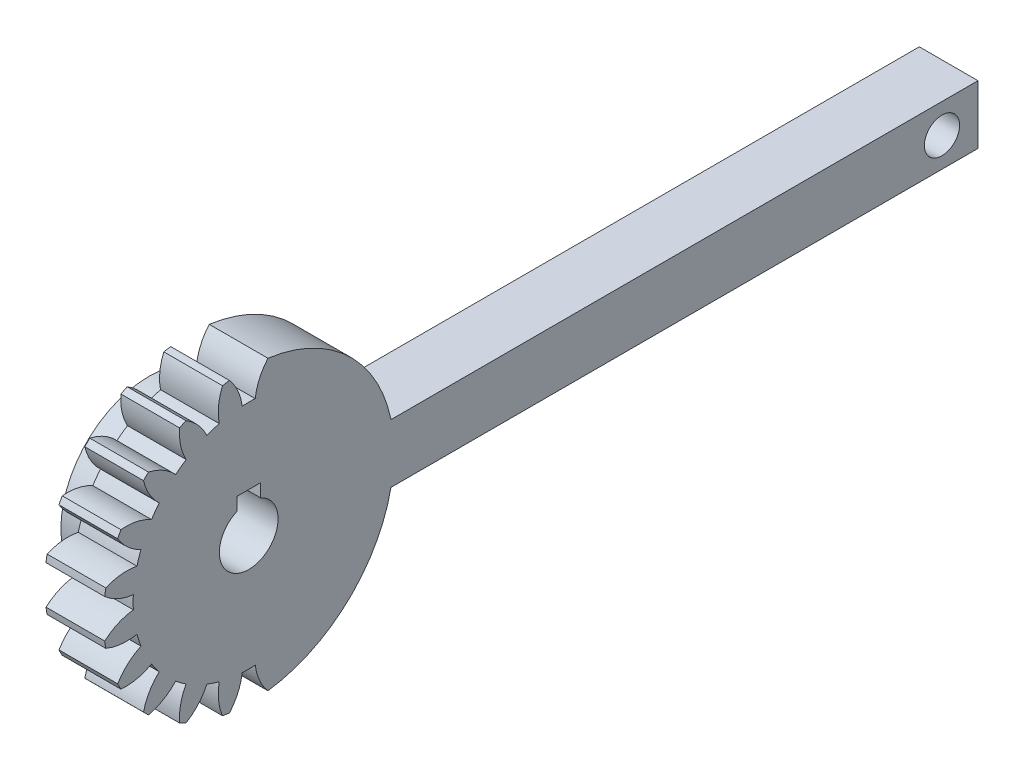
from build123d import *

# Parameters (mm, degrees)
BASPROSKE_W             = 10
BASPROSKE_H             = 24.75
TOOTHCUT_DEPTH          = 37.402266413
TEETHCUTS_COUNT         = 11
TEETHCUTS_ANGLE         = 180
HUBNEAONESKE_R          = 15
HUBNEARONE_DEPTH        = 7.0000508
BORSKE_R                = 5
BORE_DEPTH              = 10.0000508
KEYSKE_W                = 4
KEYSKE_H                = 6.8
KEYWAY_DEPTH            = 10.0000508
ESQUISSE1_W             = 100
ESQUISSE1_H             = 10
BOSS_EXTRU_1_DEPTH      = 10
ESQUISSE2_R             = 3
ENL_V_MAT_EXTRU_2_DEPTH = 10


with BuildPart() as part:
    # BasProSke → Base-Revolve (revolve)
    with BuildSketch(Plane(origin=(0, 0, 0), x_dir=(1, 0, 0), z_dir=(0, 1, 0)), mode=Mode.PRIVATE) as base_revolve_sk:
        with Locations((5, 12.375)):
            Rectangle(BASPROSKE_W, BASPROSKE_H)
    revolve(base_revolve_sk.sketch.rotate(Axis((-10, 0, 0), (1, 0, 0)), 180), axis=Axis((-10, 0, 0), (1, 0, 0)))

    # TooCutSke → ToothCut (cut, through all)
    with BuildSketch(Plane(origin=(0, 0, 0), x_dir=(0, 0, -1), z_dir=(1, 0, 0))):
        with BuildLine():
            ThreePointArc((1.111948432, 19.655071939), (0, 19.6865), (-1.111948432, 19.655071939))
            ThreePointArc((-1.111948432, 19.655071939), (-1.832349961, 22.271720111), (-3.300041734, 24.55463642))
            ThreePointArc((-3.300041734, 24.55463642), (0, 24.7754), (3.300041734, 24.55463642))
            ThreePointArc((3.300041734, 24.55463642), (1.832349961, 22.271720111), (1.111948432, 19.655071939))
        make_face()
    toothcut = extrude(amount=TOOTHCUT_DEPTH, mode=Mode.SUBTRACT)

    # TeethCuts: ToothCut ×11 about axis
    teethcuts_axis = Axis((-10, 0, 0), (1, 0, 0))
    for i in range(1, TEETHCUTS_COUNT):
        add(toothcut.rotate(teethcuts_axis, i * TEETHCUTS_ANGLE / (TEETHCUTS_COUNT - 1)), mode=Mode.SUBTRACT)

    # HubNeaOneSke → HubNearOne (add)
    with BuildSketch(Plane.ZY):
        with Locations(Location((0, 0, 0), (0, 0, 180))):
            Circle(HUBNEAONESKE_R)
    extrude(amount=HUBNEARONE_DEPTH)

    # BorSke → Bore (cut, symmetric)
    with BuildSketch(Plane(origin=(0, 0, 0), x_dir=(0, 0, -1), z_dir=(1, 0, 0))):
        with Locations(Location((0, 0, 0), (0, 0, 180))):
            Circle(BORSKE_R)
    extrude(amount=BORE_DEPTH, both=True, mode=Mode.SUBTRACT)

    # KeySke → Keyway (cut, symmetric)
    with BuildSketch(Plane(origin=(0, 0, 0), x_dir=(0, 0, -1), z_dir=(1, 0, 0))):
        with Locations((0, 3.4)):
            Rectangle(KEYSKE_W, KEYSKE_H)
    extrude(amount=KEYWAY_DEPTH, both=True, mode=Mode.SUBTRACT)

    # Esquisse1 → Boss.-Extru.1 (add)
    with BuildSketch(Plane(origin=(10, 0, 0), x_dir=(0, 0, -1), z_dir=(1, 0, 0))):
        with Locations((74.239688529, 0)):
            Rectangle(ESQUISSE1_W, ESQUISSE1_H)
    extrude(amount=-BOSS_EXTRU_1_DEPTH)

    # Esquisse2 → Enlèv. mat.-Extru.2 (cut)
    with BuildSketch(Plane.ZY):
        with Locations((-118.101402352, 0)):
            Circle(ESQUISSE2_R)
    extrude(amount=-ENL_V_MAT_EXTRU_2_DEPTH, mode=Mode.SUBTRACT)


solid = part.part
